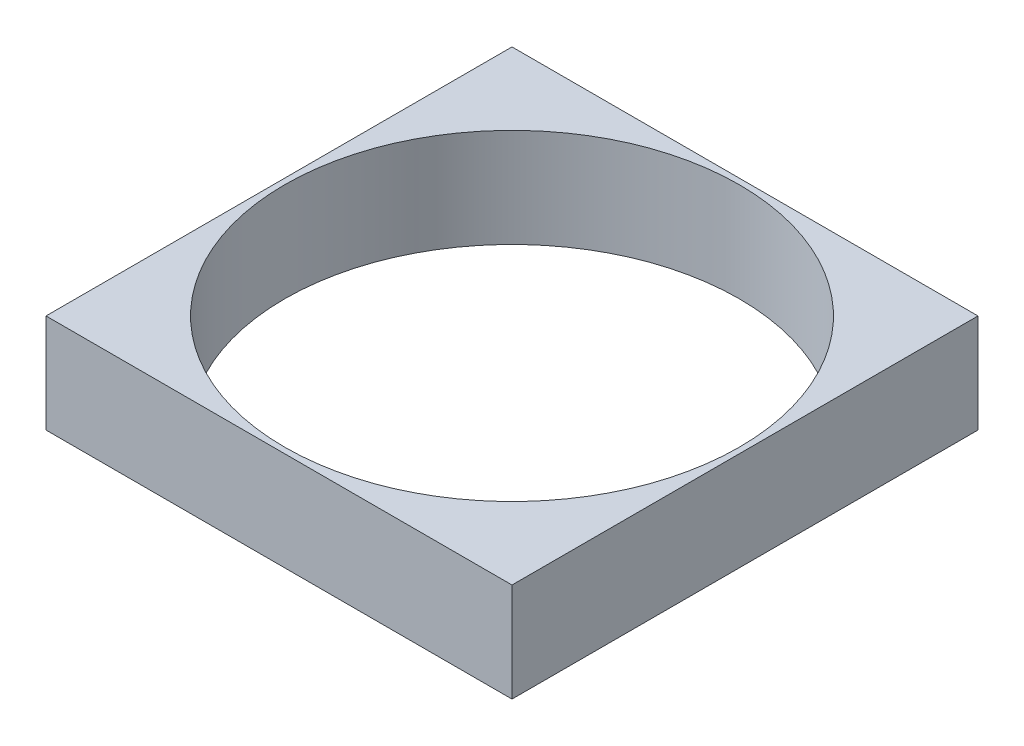
from build123d import *

# Parameters (mm, degrees)
SKETCH1_W           = 119.761
SKETCH1_H           = 119.761
BOSS_EXTRUDE1_DEPTH = 25.4
SKETCH2_R           = 58.42
CUT_EXTRUDE1_DEPTH  = 25.4


with BuildPart() as part:
    # Sketch1 → Boss-Extrude1 (new body)
    with BuildSketch(Plane(origin=(0, 0, 0), x_dir=(1, 0, 0), z_dir=(0, 1, 0))):
        with Locations((59.8805, 59.8805)):
            Rectangle(SKETCH1_W, SKETCH1_H)
    extrude(amount=BOSS_EXTRUDE1_DEPTH)

    # Sketch2 → Cut-Extrude1 (cut)
    with BuildSketch(Plane(origin=(0, 25.4, 0), x_dir=(1, 0, 0), z_dir=(0, 1, 0))):
        with Locations((59.8805, 59.8805)):
            Circle(SKETCH2_R)
    extrude(amount=-CUT_EXTRUDE1_DEPTH, mode=Mode.SUBTRACT)


solid = part.part
